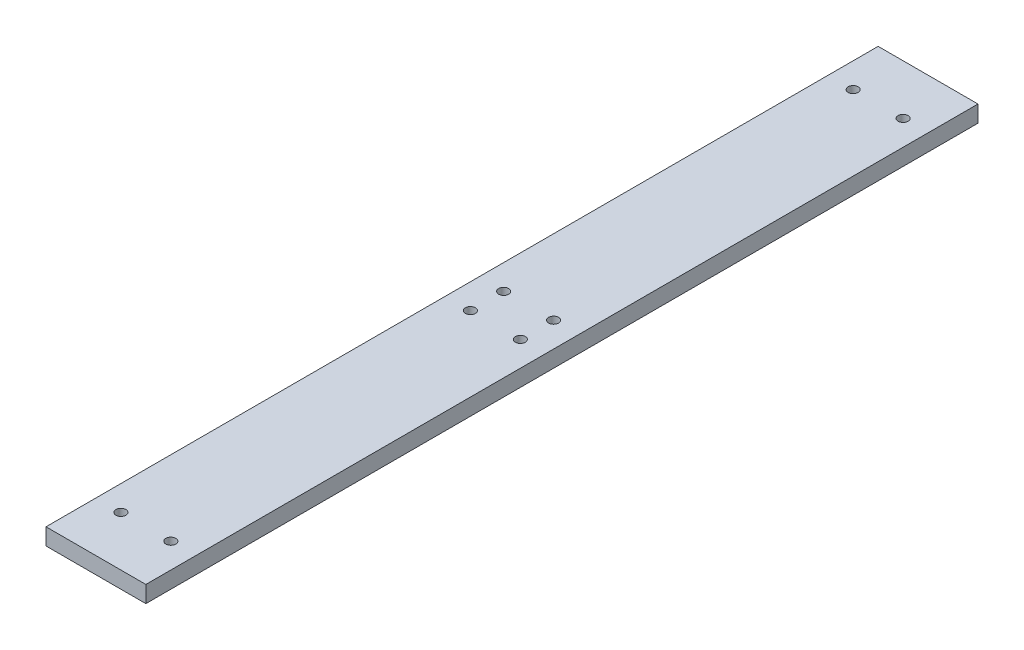
from build123d import *

# Parameters (mm, degrees)
SKETCH_1_W      = 120
SKETCH_1_H      = 1000
SKETCH_1_R      = 6
EXTRUDE_1_DEPTH = 20


with BuildPart() as part:
    # Эскиз1 → Бобышка-Вытянуть1 (new body)
    with BuildSketch(Plane(origin=(0, 0, 0), x_dir=(1, 0, 0), z_dir=(0, 1, 0))):
        with Locations((60, 500)):
            Rectangle(SKETCH_1_W, SKETCH_1_H)
        with Locations((30, 60)):
            Circle(SKETCH_1_R, mode=Mode.SUBTRACT)
        with Locations((90, 60)):
            Circle(SKETCH_1_R, mode=Mode.SUBTRACT)
        with Locations((90, 480)):
            Circle(SKETCH_1_R, mode=Mode.SUBTRACT)
        with Locations((30, 480)):
            Circle(SKETCH_1_R, mode=Mode.SUBTRACT)
        with Locations((90, 520)):
            Circle(SKETCH_1_R, mode=Mode.SUBTRACT)
        with Locations((90, 940)):
            Circle(SKETCH_1_R, mode=Mode.SUBTRACT)
        with Locations((30, 940)):
            Circle(SKETCH_1_R, mode=Mode.SUBTRACT)
        with Locations((30, 520)):
            Circle(SKETCH_1_R, mode=Mode.SUBTRACT)
    extrude(amount=EXTRUDE_1_DEPTH)


solid = part.part
